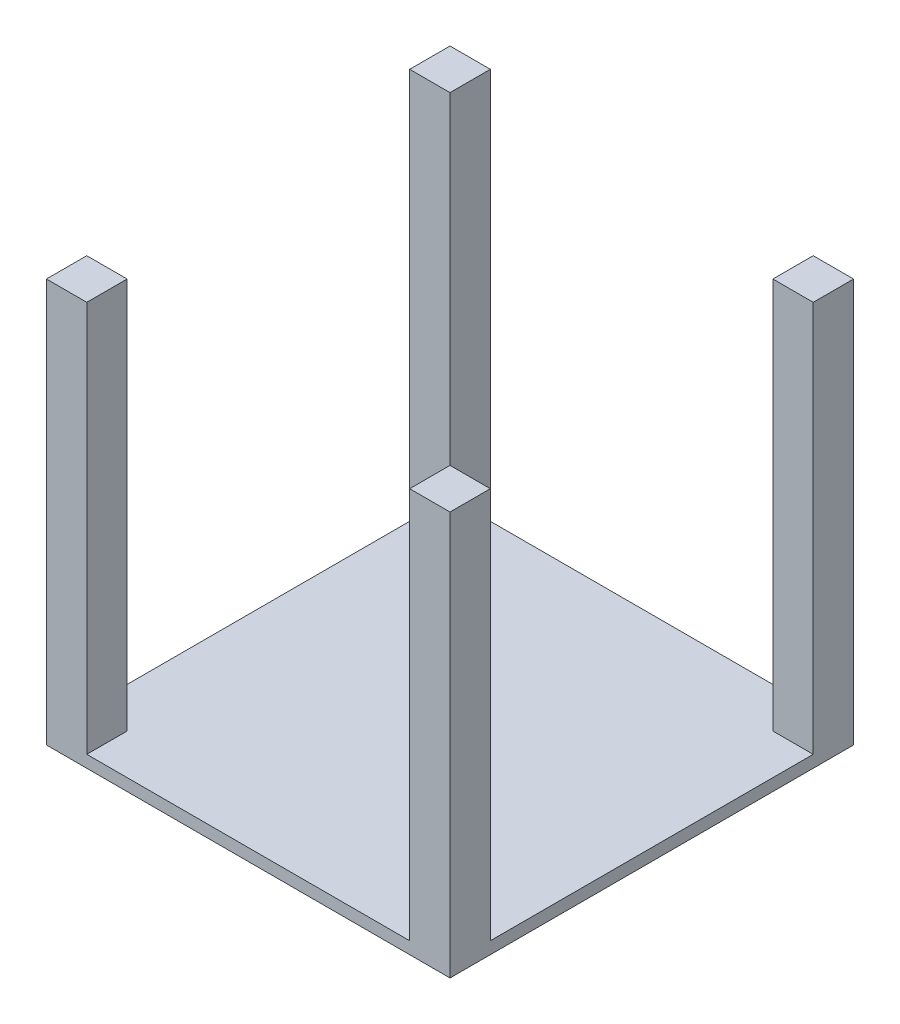
from build123d import *

# Parameters (mm, degrees)
BOSS_EXTRUDE1_DEPTH = 30
SKETCH1_3_W         = 100
SKETCH1_3_H         = 100
BOSS_EXTRUDE2_DEPTH = 1000


with BuildPart() as part:
    # Sketch1 → Boss-Extrude1 (new body)
    with BuildSketch(Plane(origin=(0, 0, 0), x_dir=(1, 0, 0), z_dir=(0, 1, 0))):
        Polygon((-400, -500), (400, -500), (400, -400), (500, -400), (500, 400), (400, 400), (400, 500), (-400, 500), (-400, 400), (-500, 400), (-500, -400), (-400, -400), align=None)
    extrude(amount=BOSS_EXTRUDE1_DEPTH)

    # Sketch1_3 → Boss-Extrude2 (add)
    with BuildSketch(Plane(origin=(0, 0, 0), x_dir=(1, 0, 0), z_dir=(0, 1, 0))):
        with Locations((450, -450)):
            Rectangle(SKETCH1_3_W, SKETCH1_3_H)
        with Locations((-450, -450)):
            Rectangle(SKETCH1_3_W, SKETCH1_3_H)
        with Locations((450, 450)):
            Rectangle(SKETCH1_3_W, SKETCH1_3_H)
        with Locations((-450, 450)):
            Rectangle(SKETCH1_3_W, SKETCH1_3_H)
    extrude(amount=BOSS_EXTRUDE2_DEPTH)


solid = part.part
